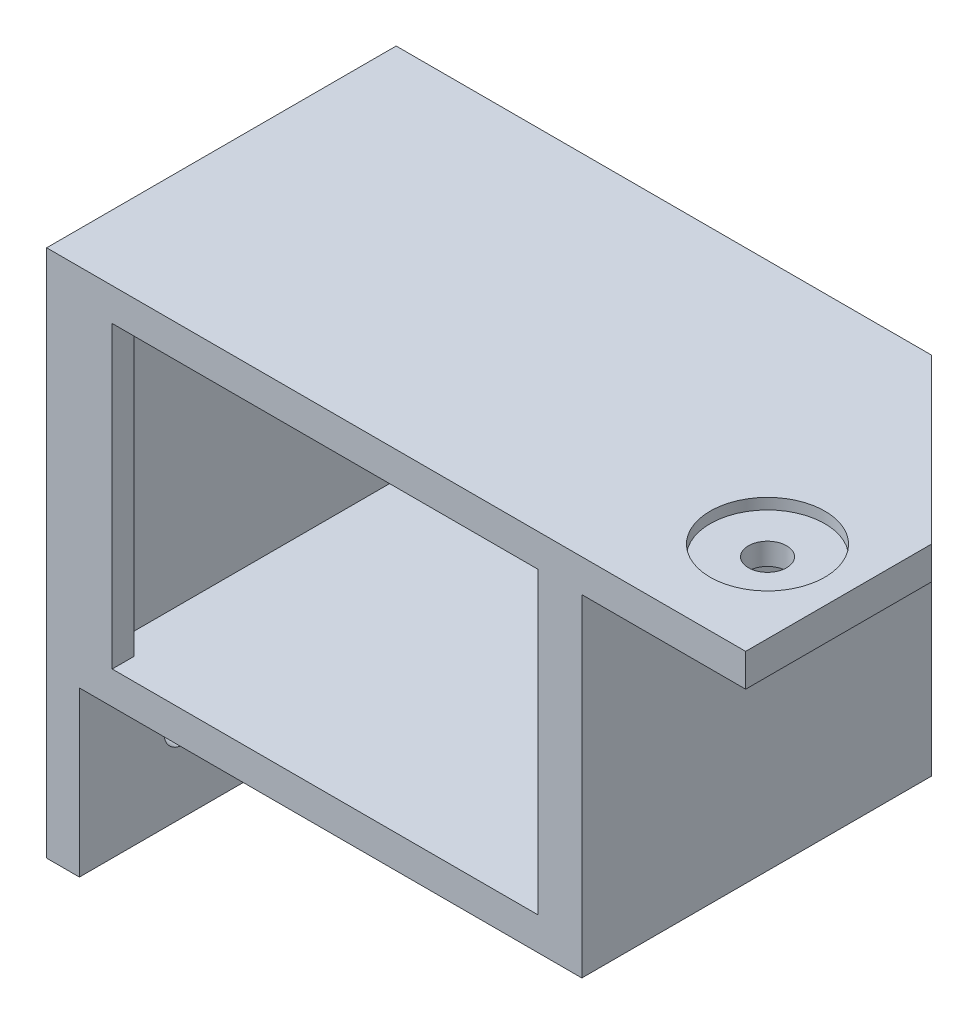
from build123d import *

# Parameters (mm, degrees)
ESBO_O1_W                = 39
ESBO_O1_H                = 27.4
RESSALTO_EXTRUS_O1_DEPTH = 32
ESBO_O2_W                = 43
ESBO_O2_H                = 27.4
CORTE_EXTRUS_O1_DEPTH    = 30
ESBO_O3_R                = 1.75
CORTE_EXTRUS_O2_DEPTH    = 6
ESBO_O4_R                = 1.75
CORTE_EXTRUS_O3_DEPTH    = 6
CHANFRO1_SIZE            = 15
ESBO_O5_R                = 5.25
CORTE_EXTRUS_O4_DEPTH    = 1
ESBO_O6_R                = 5.25
CORTE_EXTRUS_O5_DEPTH    = 1


with BuildPart() as part:
    # Esboço1 → Ressalto-extrusão1 (new body)
    with BuildSketch(Plane.XY):
        Polygon((0, 0), (64, 0), (64, -3), (49, -3), (49, -33.4), (3, -33.4), (3, -48.4), (0, -48.4), align=None)
        with Locations((25.5, -16.7)):
            Rectangle(ESBO_O1_W, ESBO_O1_H, mode=Mode.SUBTRACT)
    extrude(amount=RESSALTO_EXTRUS_O1_DEPTH)

    # Esboço2 → Corte-extrusão1 (cut)
    with BuildSketch(Plane(origin=(0, 0, 0), x_dir=(-1, 0, 0), z_dir=(0, 0, -1))):
        with Locations((-25.5, -16.7)):
            Rectangle(ESBO_O2_W, ESBO_O2_H)
    extrude(amount=-CORTE_EXTRUS_O1_DEPTH, mode=Mode.SUBTRACT)

    # Esboço3 → Corte-extrusão2 (cut)
    with BuildSketch(Plane.XZ.offset(3)):
        with Locations((56.5, 22.5)):
            Circle(ESBO_O3_R)
    extrude(amount=-CORTE_EXTRUS_O2_DEPTH, mode=Mode.SUBTRACT)

    # Esboço4 → Corte-extrusão3 (cut)
    with BuildSketch(Plane(origin=(3, 0, 0), x_dir=(0, 0, -1), z_dir=(1, 0, 0))):
        with Locations((-22.5, -40.9)):
            Circle(ESBO_O4_R)
    extrude(amount=-CORTE_EXTRUS_O3_DEPTH, mode=Mode.SUBTRACT)

    # Chanfro1
    chanfro1_edges = [part.edges().sort_by_distance(p)[0] for p in [
        (1.5, -48.4, 0),
        (64, -1.5, 0),
    ]]
    chamfer(chanfro1_edges, length=CHANFRO1_SIZE)

    # Esboço5 → Corte-extrusão4 (cut)
    with BuildSketch(Plane(origin=(0, 0, 0), x_dir=(1, 0, 0), z_dir=(0, 1, 0))):
        with Locations((56.5, -22.5)):
            Circle(ESBO_O5_R)
    extrude(amount=-CORTE_EXTRUS_O4_DEPTH, mode=Mode.SUBTRACT)

    # Esboço6 → Corte-extrusão5 (cut)
    with BuildSketch(Plane.ZY):
        with Locations((22.5, -40.9)):
            Circle(ESBO_O6_R)
    extrude(amount=-CORTE_EXTRUS_O5_DEPTH, mode=Mode.SUBTRACT)


solid = part.part
